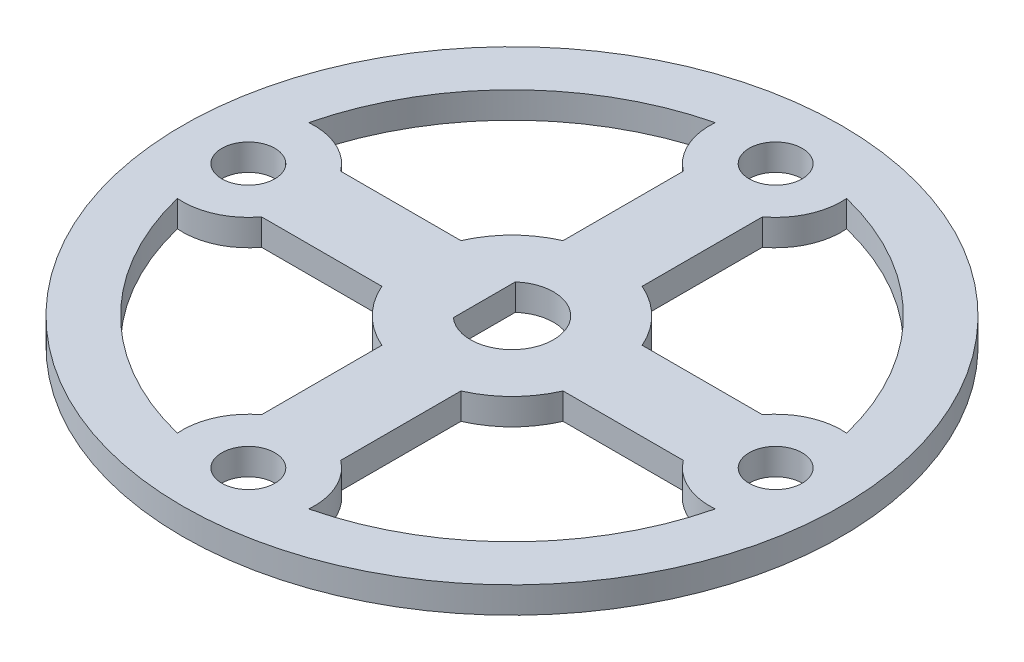
from build123d import *

# Parameters (mm, degrees)
SKETCH1_R           = 31.75
SKETCH1_R_2         = 4.000000128
BOSS_EXTRUDE1_DEPTH = 1.27
BOSS_EXTRUDE3_DEPTH = 2.54
SKETCH3_R           = 2.5527
CUT_EXTRUDE1_DEPTH  = 3.54
CUT_EXTRUDE2_DEPTH  = 3.54
CIRPATTERN1_COUNT   = 4


with BuildPart() as part:
    # Sketch1 → Boss-Extrude1 (new body, symmetric)
    with BuildSketch(Plane(origin=(0, 0, 0), x_dir=(1, 0, 0), z_dir=(0, 1, 0))):
        Circle(SKETCH1_R)
        Circle(SKETCH1_R_2, mode=Mode.SUBTRACT)
    extrude(amount=BOSS_EXTRUDE1_DEPTH, both=True)

    # Sketch2 → Boss-Extrude3 (add, through all)
    with BuildSketch(Plane(origin=(0, 1.27, 0), x_dir=(1, 0, 0), z_dir=(0, 1, 0))):
        with BuildLine():
            Line((-2.667, -2.981125966), (-2.667, 2.981125966))
            ThreePointArc((-2.667, 2.981125966), (-4.000000128, 0), (-2.667, -2.981125966))
        make_face()
    extrude(amount=-BOSS_EXTRUDE3_DEPTH)

    # Sketch3 → Cut-Extrude1 (cut, through all)
    with BuildSketch(Plane(origin=(0, 1.27, 0), x_dir=(1, 0, 0), z_dir=(0, 1, 0))):
        with Locations((0, 25.4)):
            Circle(SKETCH3_R)
    cut_extrude1 = extrude(amount=-CUT_EXTRUDE1_DEPTH, mode=Mode.SUBTRACT)

    # Sketch4 → Cut-Extrude2 (cut, through all)
    with BuildSketch(Plane(origin=(0, 1.27, 0), x_dir=(1, 0, 0), z_dir=(0, 1, 0))):
        with BuildLine():
            Line((3.81, 8.729806699), (3.81, 20.32))
            ThreePointArc((3.81, 20.32), (5.788743237, 22.789836838), (6.329647384, 25.908))
            ThreePointArc((6.329647384, 25.908), (18.858537854, 18.858537854), (25.908, 6.329647384))
            ThreePointArc((25.908, 6.329647384), (22.789836838, 5.788743237), (20.32, 3.81))
            Line((20.32, 3.81), (8.729806699, 3.81))
            ThreePointArc((8.729806699, 3.81), (6.735192091, 6.735192091), (3.81, 8.729806699))
        make_face()
    cut_extrude2 = extrude(amount=-CUT_EXTRUDE2_DEPTH, mode=Mode.SUBTRACT)

    # CirPattern1: Cut-Extrude1, Cut-Extrude2 ×4 about axis
    cirpattern1_axis = Axis((0, 0, 0), (0, 1, 0))
    for i in range(1, CIRPATTERN1_COUNT):
        add(cut_extrude1.rotate(cirpattern1_axis, i * 360 / CIRPATTERN1_COUNT), mode=Mode.SUBTRACT)
        add(cut_extrude2.rotate(cirpattern1_axis, i * 360 / CIRPATTERN1_COUNT), mode=Mode.SUBTRACT)


solid = part.part
